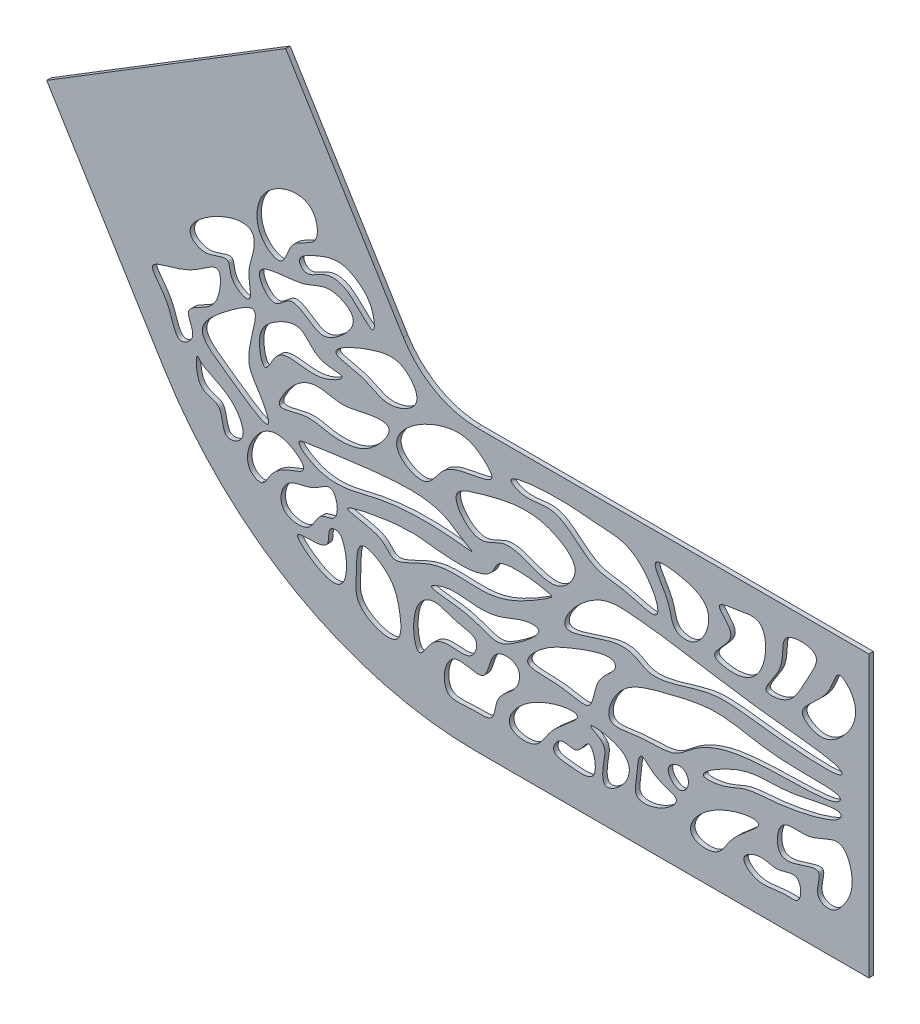
from build123d import *

# Parameters (mm, degrees)
SALIENTE_EXTRUIR1_DEPTH = 0.8


with BuildPart() as part:
    # Croquis1 → Saliente-Extruir1 (new body)
    with BuildSketch(Plane.XY):
        with BuildLine():
            ThreePointArc((-164.418717754, 9.501472757), (-140.680396522, -13.308458517), (-108.84636043, -21.698631678))
            Line((-108.84636043, -21.698631678), (-38.864788968, -21.698631678))
            Line((-38.864788968, -21.698631678), (-38.864788968, 28.301368322))
            Line((-38.864788968, 28.301368322), (-108.71786217, 28.301368322))
            ThreePointArc((-108.71786217, 28.301368322), (-116.229974662, 30.305541516), (-121.830743669, 35.698122606))
            Line((-121.830743669, 35.698122606), (-137.548733579, 61.250907057))
            Line((-137.548733579, 61.250907057), (-142.788063549, 69.768501874))
            Line((-142.788063549, 69.768501874), (-185.376037634, 43.571852025))
            Line((-185.376037634, 43.571852025), (-180.136707664, 35.054257208))
            Line((-180.136707664, 35.054257208), (-164.418717754, 9.501472757))
        make_face()
        with BuildLine():
            add(Edge.make_bspline(
                [(-132.750558661, -7.732863924), (-133.930948179, -9.097519051), (-137.658360587, -7.550708346), (-142.703396929, -2.882621335), (-134.085679399, -4.933390218), (-135.608782355, 0.023825958), (-133.151351863, 0.031132092), (-131.706915453, -2.935986963), (-131.698167503, -6.516188438), (-132.750558661, -7.732863924)],
                knots=[0, 0, 0, 0, 0.243328746, 0.360778765, 0.579241042, 0.68850296, 0.751907485, 0.783057189, 1, 1, 1, 1], degree=3))
        make_face(mode=Mode.SUBTRACT)
        with BuildLine():
            add(Edge.make_bspline(
                [(-122.979834341, -11.465545712), (-124.389764247, -12.703857619), (-130.845232021, -10.385097871), (-130.054082595, -5.11398007), (-130.30423011, 1.692587352), (-123.818400127, -2.145019934), (-122.460491595, -6.214021628), (-121.941716732, -10.553788758), (-122.979834341, -11.465545712)],
                knots=[0, 0, 0, 0, 0.222452767, 0.374090587, 0.524163471, 0.69500756, 0.836210202, 1, 1, 1, 1], degree=3))
        make_face(mode=Mode.SUBTRACT)
        with BuildLine():
            add(Edge.make_bspline(
                [(-113.934716349, -7.732863924), (-112.38731323, -7.659843877), (-109.545296966, -8.612679237), (-108.113598616, -3.965132805), (-112.794774195, -3.681541017), (-116.343183561, -1.471360508), (-120.807200321, -4.928789663), (-119.609099597, -14.11105881), (-116.934489587, -8.559382418), (-115.020206917, -7.784086886), (-113.934716349, -7.732863924)],
                knots=[0, 0, 0, 0, 0.139916068, 0.219186822, 0.321205217, 0.480173691, 0.591383831, 0.803097746, 0.901850028, 1, 1, 1, 1], degree=3))
        make_face(mode=Mode.SUBTRACT)
        with BuildLine():
            add(Edge.make_bspline(
                [(-158.26552733, 14.239169961), (-157.120890809, 12.778058851), (-152.293154931, 12.128413698), (-149.156130548, 5.526170753), (-154.356394435, 3.76751147), (-153.625058939, 10.013099571), (-158.835109616, 8.636074277), (-158.83182798, 15.033491756), (-158.320313356, 14.309103489), (-158.26552733, 14.239169961)],
                knots=[0, 0, 0, 0, 0.265528261, 0.469360305, 0.552103019, 0.711780294, 0.872909541, 0.987290954, 1, 1, 1, 1], degree=3))
        make_face(mode=Mode.SUBTRACT)
        with BuildLine():
            add(Edge.make_bspline(
                [(-161.151383163, 15.361413307), (-160.506505659, 15.474843202), (-158.300883377, 17.245505837), (-161.524825985, 21.004279109), (-156.487776286, 22.578192135), (-154.452880195, 25.36613798), (-154.109702295, 31.654809506), (-160.057994153, 25.632235789), (-169.05336714, 25.37910673), (-163.081046232, 20.387663438), (-162.593358036, 15.107778999), (-161.151383163, 15.361413307)],
                knots=[0, 0, 0, 0, 0.058502956, 0.146138354, 0.242131673, 0.335972771, 0.426325966, 0.560433079, 0.746383781, 0.869184779, 1, 1, 1, 1], degree=3))
        make_face(mode=Mode.SUBTRACT)
        with BuildLine():
            add(Edge.make_bspline(
                [(-148.529013504, 26.606152961), (-147.366697345, 26.121078437), (-150.794622401, 18.583643554), (-147.572296995, 14.756372919), (-144.013560713, 7.649231907), (-153.024810614, 14.320976933), (-159.725626937, 18.703314175), (-153.974482692, 23.625066716), (-149.243452347, 26.904312871), (-148.529013504, 26.606152961)],
                knots=[0, 0, 0, 0, 0.192488493, 0.293021905, 0.387178268, 0.573903956, 0.7207295, 0.881683434, 1, 1, 1, 1], degree=3))
        make_face(mode=Mode.SUBTRACT)
        with BuildLine():
            add(Edge.make_bspline(
                [(-148.529013504, 1.023956098), (-148.089357161, 0.712934397), (-146.770287151, 0.246090341), (-145.717942292, 2.505415709), (-144.044861593, 4.237047665), (-141.866688357, 5.196443052), (-138.308001839, 6.352849251), (-142.779465273, 9.96406684), (-148.128174542, 9.325734274), (-150.738705628, 2.587136556), (-148.529013504, 1.023956098)],
                knots=[0, 0, 0, 0, 0.055985811, 0.125037127, 0.23029002, 0.322646398, 0.406347496, 0.541942889, 0.718617944, 1, 1, 1, 1], degree=3))
        make_face(mode=Mode.SUBTRACT)
        with BuildLine():
            add(Edge.make_bspline(
                [(-143.264251918, -1.332564927), (-142.420071246, -2.631482818), (-138.009454013, -3.208205071), (-137.199211248, 1.26418141), (-132.843605726, 1.092275602), (-134.049800589, 7.581368671), (-138.270497874, 3.426609823), (-142.888184999, 4.186696356), (-143.994689053, -0.208661131), (-143.264251918, -1.332564927)],
                knots=[0, 0, 0, 0, 0.167630555, 0.302485094, 0.389235511, 0.54286421, 0.656709835, 0.854955715, 1, 1, 1, 1], degree=3))
        make_face(mode=Mode.SUBTRACT)
        with BuildLine():
            add(Edge.make_bspline(
                [(-95.398215789, 8.977867044), (-96.031688103, 9.440952837), (-104.94865966, 10.961932835), (-106.286334971, 4.005267415), (-119.008435487, 6.604851575), (-121.498821228, 6.108875393), (-121.924154008, 6.675563113), (-135.678468099, 4.052603223), (-124.989750587, 3.353267231), (-123.989614966, -0.748809183), (-114.115649126, 5.684213162), (-106.544282337, 1.325245933), (-95.970784216, 8.279229481), (-95.286849874, 8.896455478), (-95.398215789, 8.977867044)],
                knots=[0, 0, 0, 0, 0.069569252, 0.096182152, 0.247246019, 0.281230851, 0.417147488, 0.513763433, 0.586005243, 0.643686918, 0.716355078, 0.877695627, 0.987769563, 1, 1, 1, 1], degree=3))
        make_face(mode=Mode.SUBTRACT)
        with BuildLine():
            add(Edge.make_bspline(
                [(-110.442415673, 9.292952075), (-113.468774378, 10.963144972), (-114.925871774, 14.260174274), (-133.562340134, 11.595871628), (-141.70515967, 10.40525578), (-135.2309758, 5.879659508), (-119.80858701, 11.379913778), (-107.341345157, 7.710564505), (-110.175107582, 9.145429551), (-110.442415673, 9.292952075)],
                knots=[0, 0, 0, 0, 0.352571417, 0.531394163, 0.556103656, 0.599666344, 0.688585519, 0.968858552, 1, 1, 1, 1], degree=3))
        make_face(mode=Mode.SUBTRACT)
        with BuildLine():
            add(Edge.make_bspline(
                [(-124.44823475, 20.462519424), (-123.932438756, 19.62715925), (-126.941397484, 15.707967161), (-130.595899788, 14.125821502), (-135.271927768, 14.004192786), (-138.840722188, 15.536300222), (-145.121767358, 12.932443942), (-141.838601739, 18.630191431), (-138.030150687, 21.268068925), (-132.910049046, 19.527936367), (-129.233996814, 20.563967303), (-124.942327544, 21.262730064), (-124.44823475, 20.462519424)],
                knots=[0, 0, 0, 0, 0.112893572, 0.206029854, 0.295443142, 0.404189701, 0.500293404, 0.567623307, 0.713389071, 0.812880605, 0.891856662, 1, 1, 1, 1], degree=3))
        make_face(mode=Mode.SUBTRACT)
        with BuildLine():
            add(Edge.make_bspline(
                [(-132.750558661, 24.135315829), (-132.593343825, 23.721396844), (-138.544589191, 20.284745572), (-143.664571568, 24.568824267), (-146.606260931, 17.040239486), (-148.21784806, 23.620242157), (-145.256762984, 26.652099677), (-139.598195591, 29.068772785), (-137.670247932, 24.13560596), (-132.906132896, 24.544915399), (-132.750558661, 24.135315829)],
                knots=[0, 0, 0, 0, 0.098282301, 0.334563157, 0.412197437, 0.510952701, 0.647917281, 0.770791139, 0.902743315, 1, 1, 1, 1], degree=3))
        make_face(mode=Mode.SUBTRACT)
        with BuildLine():
            add(Edge.make_bspline(
                [(-122.600309958, 17.401855754), (-121.744926652, 16.103919137), (-116.928907289, 13.759049084), (-114.931497137, 21.416917054), (-103.828634225, 20.302264254), (-108.413909164, 25.045855832), (-114.31233806, 27.521816768), (-124.87692741, 20.856336491), (-122.600309958, 17.401855754)],
                knots=[0, 0, 0, 0, 0.125652632, 0.26757317, 0.479331352, 0.540239917, 0.665573349, 1, 1, 1, 1], degree=3))
        make_face(mode=Mode.SUBTRACT)
        with BuildLine():
            add(Edge.make_bspline(
                [(-102.451326973, -15.11241118), (-101.662757026, -15.82559786), (-97.948024138, -16.19372343), (-95.887265918, -11.926785411), (-93.290284371, -9.91435551), (-88.603591367, -5.873799414), (-99.927477807, -7.795585692), (-103.766350052, -13.923097603), (-102.451326973, -15.11241118)],
                knots=[0, 0, 0, 0, 0.13121694, 0.261967856, 0.433385636, 0.495907082, 0.781181993, 1, 1, 1, 1], degree=3))
        make_face(mode=Mode.SUBTRACT)
        with BuildLine():
            add(Edge.make_bspline(
                [(-93.828658178, -12.572006138), (-94.553591428, -12.882063854), (-95.899437159, -15.261555441), (-91.498908436, -15.64057865), (-86.508970211, -16.312639263), (-88.497925323, -8.513639016), (-90.704372985, -13.711405828), (-92.924970071, -12.185494041), (-93.828658178, -12.572006138)],
                knots=[0, 0, 0, 0, 0.11702101, 0.265473491, 0.499789655, 0.707726475, 0.854123817, 1, 1, 1, 1], degree=3))
        make_face(mode=Mode.SUBTRACT)
        with BuildLine():
            add(Edge.make_bspline(
                [(-88.349105258, -7.732863924), (-88.072371281, -8.006726824), (-85.309581455, -9.127583431), (-86.309607533, -12.109418124), (-86.423622676, -16.508312605), (-81.889543267, -13.863328389), (-80.159353876, -7.822459052), (-89.068819122, -7.020616992), (-88.349105258, -7.732863924)],
                knots=[0, 0, 0, 0, 0.100831532, 0.25515108, 0.381411636, 0.512576107, 0.737763133, 1, 1, 1, 1], degree=3))
        make_face(mode=Mode.SUBTRACT)
        with BuildLine():
            add(Edge.make_bspline(
                [(-79.388560127, -7.732863924), (-80.022054484, -7.832196216), (-80.117991308, -11.22035281), (-80.968766225, -15.068254353), (-76.050105346, -14.727009526), (-71.405451277, -10.712274247), (-76.8185278, -10.324044826), (-78.875146541, -7.652360367), (-79.388560127, -7.732863924)],
                knots=[0, 0, 0, 0, 0.174988013, 0.298355592, 0.478987194, 0.673221019, 0.858181494, 1, 1, 1, 1], degree=3))
        make_face(mode=Mode.SUBTRACT)
        with BuildLine():
            add(Edge.make_bspline(
                [(-105.047211011, -4.766909076), (-103.979574651, -4.056567289), (-100.797519669, -4.341345178), (-101.284822083, -9.220744538), (-105.546399818, -10.577423095), (-105.419821707, -15.98702963), (-109.902413539, -15.296172257), (-115.424286852, -16.627376528), (-114.069000686, -7.087542043), (-106.28499774, -11.573268111), (-106.615109518, -5.810095565), (-105.047211011, -4.766909076)],
                knots=[0, 0, 0, 0, 0.092810056, 0.157707731, 0.299307784, 0.383949237, 0.472165592, 0.585252482, 0.732512472, 0.863701955, 1, 1, 1, 1], degree=3))
        make_face(mode=Mode.SUBTRACT)
        with BuildLine():
            add(Edge.make_bspline(
                [(-97.987922303, 2.831802579), (-96.614479735, 2.328553316), (-101.683308951, -1.579861418), (-105.060160175, -3.390334855), (-109.314880416, -1.524648896), (-112.03272962, -1.024510963), (-118.052703341, -0.467791604), (-113.716956991, 1.251946609), (-110.381533614, 0.743141669), (-104.709519517, 0.443432636), (-100.405458426, 3.181217817), (-98.14789014, 2.890417113), (-97.987922303, 2.831802579)],
                knots=[0, 0, 0, 0, 0.157145251, 0.229142337, 0.313252071, 0.454214245, 0.526143365, 0.577742492, 0.684402053, 0.816969515, 0.981696951, 1, 1, 1, 1], degree=3))
        make_face(mode=Mode.SUBTRACT)
        with BuildLine():
            add(Edge.make_bspline(
                [(-84.036108794, 3.685568692), (-84.164182588, 2.68403277), (-88.059687956, 0.654077566), (-87.721108462, -4.968640295), (-90.954060904, -4.78066433), (-94.561946303, -3.824455025), (-101.675789717, -4.539207524), (-97.161278943, 0.359225872), (-92.368849808, 2.650903537), (-84.250711844, 5.551212069), (-84.014724799, 3.852791347), (-84.036108794, 3.685568692)],
                knots=[0, 0, 0, 0, 0.100037862, 0.223752743, 0.272835489, 0.361931863, 0.526926229, 0.683101427, 0.832970576, 0.983297058, 1, 1, 1, 1], degree=3))
        make_face(mode=Mode.SUBTRACT)
        with BuildLine():
            add(Edge.make_bspline(
                [(-70.178061305, -15.597304481), (-69.389491359, -16.310491161), (-65.67475847, -16.678616731), (-63.61400025, -12.411678711), (-61.017018703, -10.399248811), (-56.330325699, -6.358692715), (-67.654212139, -8.280478993), (-71.493084384, -14.407990904), (-70.178061305, -15.597304481)],
                knots=[0, 0, 0, 0, 0.13121694, 0.261967856, 0.433385636, 0.495907082, 0.781181993, 1, 1, 1, 1], degree=3))
        make_face(mode=Mode.SUBTRACT)
        with BuildLine():
            add(Edge.make_bspline(
                [(-51.679181583, -12.688572802), (-50.795457706, -13.343291238), (-50.704971075, -16.556387707), (-55.190478429, -15.939453166), (-58.424263247, -17.654332064), (-62.1608765, -14.01384451), (-57.96115127, -12.034168429), (-55.22740241, -13.725078301), (-52.474637883, -12.099248559), (-51.679181583, -12.688572802)],
                knots=[0, 0, 0, 0, 0.160267158, 0.21076581, 0.504986522, 0.580130515, 0.727204348, 0.85574055, 1, 1, 1, 1], degree=3))
        make_face(mode=Mode.SUBTRACT)
        with BuildLine():
            add(Edge.make_bspline(
                [(-74.593465411, -7.19575575), (-74.810275752, -8.23042368), (-72.569797773, -10.614766664), (-70.518964514, -7.825063004), (-71.931128898, -5.13097743), (-74.397505419, -6.260590401), (-74.593465411, -7.19575575)],
                knots=[0, 0, 0, 0, 0.304007816, 0.526233533, 0.725228194, 1, 1, 1, 1], degree=3))
        make_face(mode=Mode.SUBTRACT)
        with BuildLine():
            add(Edge.make_bspline(
                [(-43.929779225, 3.406963808), (-44.114116876, 4.404801451), (-56.657446964, 3.494372385), (-65.140548235, 6.729507741), (-75.303156795, 4.083700469), (-83.556122792, 1.973655319), (-86.682753918, -6.344835777), (-78.875051338, -4.506245822), (-73.663272556, -5.230681894), (-69.351560827, -0.903502195), (-60.289393136, 2.590355336), (-45.176187138, 1.170313796), (-43.898911502, 3.239873819), (-43.929779225, 3.406963808)],
                knots=[0, 0, 0, 0, 0.114550047, 0.246019978, 0.351313901, 0.440260507, 0.519920021, 0.570512894, 0.6558102, 0.704961009, 0.808183564, 0.980818356, 1, 1, 1, 1], degree=3))
        make_face(mode=Mode.SUBTRACT)
        with BuildLine():
            add(Edge.make_bspline(
                [(-54.363344144, -5.9471273), (-53.348786175, -4.838645478), (-49.073379315, -6.291759741), (-43.565210909, -1.493051046), (-41.166918824, -8.485184998), (-42.812859839, -12.2636623), (-45.331761401, -15.029447281), (-48.968660174, -13.833460689), (-45.729854654, -6.991659828), (-55.768795022, -13.770025277), (-55.359345491, -7.0353346), (-54.363344144, -5.9471273)],
                knots=[0, 0, 0, 0, 0.115773361, 0.264232273, 0.386481489, 0.502340138, 0.579489949, 0.628580772, 0.723680545, 0.886344174, 1, 1, 1, 1], degree=3))
        make_face(mode=Mode.SUBTRACT)
        with BuildLine():
            add(Edge.make_bspline(
                [(-43.846906731, 1.03380609), (-44.363519162, 1.958158781), (-55.24002578, -1.399836503), (-60.063312735, 0.758273118), (-70.544218151, -5.719309396), (-64.429380133, -5.269336222), (-60.829458046, -3.071799844), (-54.310047703, -3.206486551), (-43.867972505, -0.767243402), (-43.777599374, 0.909797379), (-43.846906731, 1.03380609)],
                knots=[0, 0, 0, 0, 0.173914473, 0.388452632, 0.503873436, 0.557098589, 0.647485373, 0.766680945, 0.976668095, 1, 1, 1, 1], degree=3))
        make_face(mode=Mode.SUBTRACT)
        with BuildLine():
            add(Edge.make_bspline(
                [(-93.828658178, 11.280528413), (-96.960705079, 9.782215566), (-102.36805812, 15.191551256), (-108.649681765, 9.50212908), (-114.500977282, 16.497793514), (-104.307950905, 19.567893613), (-97.263378788, 21.21847807), (-89.930291562, 15.357016315), (-92.349675033, 11.988046377), (-93.828658178, 11.280528413)],
                knots=[0, 0, 0, 0, 0.209596739, 0.303825911, 0.431795946, 0.517021949, 0.822043447, 0.901026372, 1, 1, 1, 1], degree=3))
        make_face(mode=Mode.SUBTRACT)
        with BuildLine():
            add(Edge.make_bspline(
                [(-102.344654621, 22.798053413), (-102.128097132, 22.62416791), (-99.760745135, 21.346580702), (-94.099420789, 23.914047831), (-88.824402943, 16.449047109), (-82.580714411, 16.803420981), (-74.165578022, 13.430757117), (-79.679409409, 24.139094717), (-87.745971371, 23.950869434), (-92.838358137, 25.042393459), (-103.884778554, 24.034700669), (-102.344654621, 22.798053413)],
                knots=[0, 0, 0, 0, 0.018173889, 0.122894497, 0.279653893, 0.384629408, 0.472626168, 0.608786908, 0.726153064, 0.870750066, 1, 1, 1, 1], degree=3))
        make_face(mode=Mode.SUBTRACT)
        with BuildLine():
            add(Edge.make_bspline(
                [(-44.087470322, 7.922646), (-45.664122566, 8.863234493), (-61.158785454, 9.868229946), (-75.798492875, 13.097526105), (-88.942634666, 13.599728662), (-97.49812899, 1.966265439), (-81.672356279, 9.224453435), (-78.231462315, 3.835830981), (-67.253265777, 9.198567317), (-59.108553815, 7.482057188), (-42.406068893, 6.17230926), (-43.841685999, 7.776017657), (-44.087470322, 7.922646)],
                knots=[0, 0, 0, 0, 0.099677328, 0.267067778, 0.297767809, 0.406677629, 0.47274056, 0.561818037, 0.712100252, 0.844613011, 0.984461301, 1, 1, 1, 1], degree=3))
        make_face(mode=Mode.SUBTRACT)
        with BuildLine():
            add(Edge.make_bspline(
                [(-76.837952102, 23.421160972), (-77.403926288, 22.564951857), (-74.047260383, 18.866829549), (-74.096177532, 14.663397564), (-69.051819786, 13.473208594), (-65.6688813, 21.057357285), (-71.407421658, 23.600715705), (-76.358800953, 24.146023681), (-76.837952102, 23.421160972)],
                knots=[0, 0, 0, 0, 0.195722298, 0.325152471, 0.402012975, 0.648328218, 0.8343024, 1, 1, 1, 1], degree=3))
        make_face(mode=Mode.SUBTRACT)
        with BuildLine():
            add(Edge.make_bspline(
                [(-65.502090263, 22.400939749), (-65.627627324, 21.722561611), (-60.783299051, 18.622628717), (-68.64789997, 14.289781183), (-61.930016551, 12.738697206), (-56.98913741, 15.354866953), (-56.832141062, 24.573318685), (-61.883932088, 23.390577477), (-65.397083778, 22.968374604), (-65.502090263, 22.400939749)],
                knots=[0, 0, 0, 0, 0.113933947, 0.288077368, 0.377523831, 0.561215078, 0.781648315, 0.904699033, 1, 1, 1, 1], degree=3))
        make_face(mode=Mode.SUBTRACT)
        with BuildLine():
            add(Edge.make_bspline(
                [(-50.516244537, 12.766067355), (-51.602750807, 14.480574053), (-45.707110665, 16.978539736), (-44.682239405, 23.682780405), (-39.680638702, 18.814972579), (-42.724373262, 13.21988883), (-47.315621638, 10.559199771), (-50.088267312, 12.090719372), (-50.516244537, 12.766067355)],
                knots=[0, 0, 0, 0, 0.267800279, 0.390798431, 0.490723643, 0.760932173, 0.894512878, 1, 1, 1, 1], degree=3))
        make_face(mode=Mode.SUBTRACT)
        with BuildLine():
            add(Edge.make_bspline(
                [(-53.364224327, 23.578998877), (-54.713172058, 22.593963484), (-52.99411731, 18.363144432), (-58.824690145, 13.059775128), (-52.351650642, 13.345371415), (-50.83041158, 17.696979175), (-46.532755015, 24.368855207), (-52.153067218, 24.46341611), (-53.364224327, 23.578998877)],
                knots=[0, 0, 0, 0, 0.18416172, 0.363281009, 0.422910842, 0.690341932, 0.834649801, 1, 1, 1, 1], degree=3))
        make_face(mode=Mode.SUBTRACT)
        with BuildLine():
            add(Edge.make_bspline(
                [(-152.350127578, 29.538080246), (-151.69647233, 28.280122327), (-148.250286873, 26.534653784), (-149.924960551, 32.109357267), (-148.514002754, 34.682699413), (-148.107457696, 40.284369334), (-155.970916878, 38.207072637), (-161.426793133, 32.897840288), (-156.690182626, 30.313445673), (-152.597029837, 33.195703987), (-152.805058385, 30.413593465), (-152.350127578, 29.538080246)],
                knots=[0, 0, 0, 0, 0.094970088, 0.186426608, 0.312722587, 0.374421347, 0.581872069, 0.745185529, 0.825555173, 0.933902743, 1, 1, 1, 1], degree=3))
        make_face(mode=Mode.SUBTRACT)
        with BuildLine():
            add(Edge.make_bspline(
                [(-136.317329267, 28.836967199), (-138.307901019, 29.025491332), (-141.393784534, 33.281170575), (-144.829734368, 28.052595483), (-150.238637815, 35.056631464), (-139.685215847, 33.903547628), (-135.449827832, 37.45938854), (-128.870686862, 34.392917416), (-132.955544798, 30.021253895), (-135.449436074, 28.754770307), (-136.317329267, 28.836967199)],
                knots=[0, 0, 0, 0, 0.160698353, 0.236870346, 0.338533375, 0.549422427, 0.677618573, 0.794023517, 0.929935202, 1, 1, 1, 1], degree=3))
        make_face(mode=Mode.SUBTRACT)
        with BuildLine():
            add(Edge.make_bspline(
                [(-119.41258008, 27.185486409), (-119.215385111, 28.562927249), (-121.871195912, 31.994586941), (-127.167772064, 31.457716235), (-137.240248925, 26.968546247), (-128.470564616, 26.220784024), (-124.838413562, 22.947926715), (-119.66889459, 25.395085399), (-119.41258008, 27.185486409)],
                knots=[0, 0, 0, 0, 0.136646705, 0.282005956, 0.527241205, 0.667765019, 0.822386275, 1, 1, 1, 1], degree=3))
        make_face(mode=Mode.SUBTRACT)
        with BuildLine():
            add(Edge.make_bspline(
                [(-127.091690965, 34.254658921), (-127.560983314, 33.386526277), (-131.456862272, 38.716351255), (-135.846525605, 38.947193839), (-139.018605277, 36.300140512), (-141.098918612, 38.795409277), (-136.522982781, 41.009280483), (-133.006763556, 42.09640542), (-129.225528692, 39.920246734), (-127.255113749, 37.746591648), (-126.863615082, 34.676571018), (-127.091690965, 34.254658921)],
                knots=[0, 0, 0, 0, 0.171739551, 0.311460853, 0.41465251, 0.444426764, 0.554647312, 0.716530557, 0.806041395, 0.916534651, 1, 1, 1, 1], degree=3))
        make_face(mode=Mode.SUBTRACT)
        with BuildLine():
            add(Edge.make_bspline(
                [(-145.836743071, 37.186586206), (-145.208027645, 36.716639541), (-142.884202348, 35.67751561), (-142.289190187, 41.283113501), (-136.544745946, 41.652297805), (-137.594666624, 49.903468081), (-148.685919663, 47.175982099), (-148.427368594, 39.123004138), (-145.836743071, 37.186586206)],
                knots=[0, 0, 0, 0, 0.063822483, 0.191703494, 0.344683935, 0.476022199, 0.737019092, 1, 1, 1, 1], degree=3))
        make_face(mode=Mode.SUBTRACT)
    extrude(amount=SALIENTE_EXTRUIR1_DEPTH)


solid = part.part
